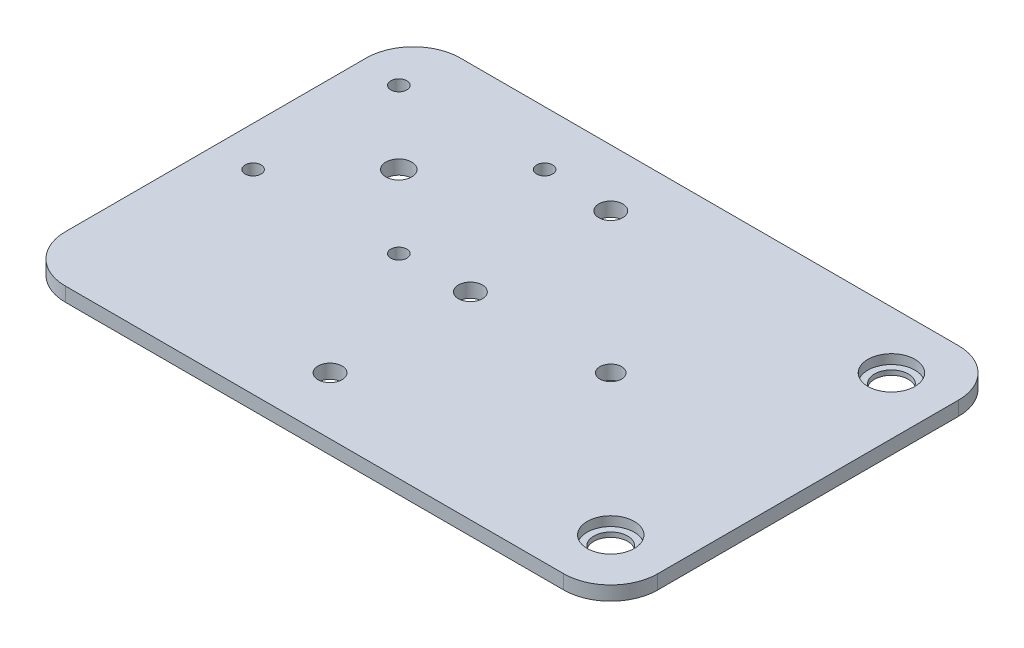
from build123d import *

# Parameters (mm, degrees)
BOSS_EXTRUDE1_DEPTH              = 3
F_4_6_4_6_DIAMETER_HOLE1_D       = 4.6
CBORE_FOR_M6_5_SHSS1_D           = 7.2
CBORE_FOR_M6_5_SHSS1_CBORE_D     = 10
CBORE_FOR_M6_5_SHSS1_CBORE_DEPTH = 2
M10X1_0_TAPPED_HOLE1_D           = 5.1
F_3_0MM_DOWEL_HOLE1_D            = 3.4
F_5_0MM_DOWEL_HOLE1_D            = 5.5
FILLET3_R                        = 10


with BuildPart() as part:
    # Sketch1 → Boss-Extrude1 (new body)
    with BuildSketch(Plane(origin=(0, 6, 0), x_dir=(1, 0, 0), z_dir=(0, 1, 0))):
        Polygon((42, 42), (-42, 42), (-84, 42), (-84, -42), (-42, -42), (42, -42), align=None)
    extrude(amount=-BOSS_EXTRUDE1_DEPTH)

    # Ø4.6 (4.6) Diameter Hole1 (through all)
    with Locations(Plane(origin=(0, 3, 0), x_dir=(-1, 0, 0), z_dir=(0, -1, 0))):
        with Locations((0, 0)):
            Hole(F_4_6_4_6_DIAMETER_HOLE1_D / 2)

    # CBORE for M6.5 SHSS1 (through all)
    with Locations(Plane(origin=(0, 6, 0), x_dir=(1, 0, 0), z_dir=(0, 1, 0))):
        with Locations((29.85, 29.85), (29.85, -29.85)):
            CounterBoreHole(CBORE_FOR_M6_5_SHSS1_D / 2, CBORE_FOR_M6_5_SHSS1_CBORE_D / 2, CBORE_FOR_M6_5_SHSS1_CBORE_DEPTH)

    # M10x1.0 Tapped Hole1 (through all)
    with Locations(Plane(origin=(0, 6, 0), x_dir=(1, 0, 0), z_dir=(0, 1, 0))):
        with Locations((-29.85, -29.85), (-29.85, 29.85), (-29.85, 0)):
            Hole(M10X1_0_TAPPED_HOLE1_D / 2)

    # Ø3.0mm Dowel Hole1 (through all)
    with Locations(Plane(origin=(0, 6, 0), x_dir=(1, 0, 0), z_dir=(0, 1, 0))):
        with Locations((-75.5, 30.425), (-44.5, 30.425), (-44.5, -0.575), (-75.5, -0.575)):
            Hole(F_3_0MM_DOWEL_HOLE1_D / 2)

    # Ø5.0mm Dowel Hole1 (through all)
    with Locations(Plane(origin=(0, 6, 0), x_dir=(1, 0, 0), z_dir=(0, 1, 0))):
        with Locations((-60, 14.925)):
            Hole(F_5_0MM_DOWEL_HOLE1_D / 2)

    # Fillet3
    fillet3_edges = [part.edges().sort_by_distance(p)[0] for p in [
        (42, 4.5, -42),
        (42, 4.5, 42),
        (-84, 4.5, 42),
        (-84, 4.5, -42),
    ]]
    fillet(fillet3_edges, radius=FILLET3_R)


solid = part.part
